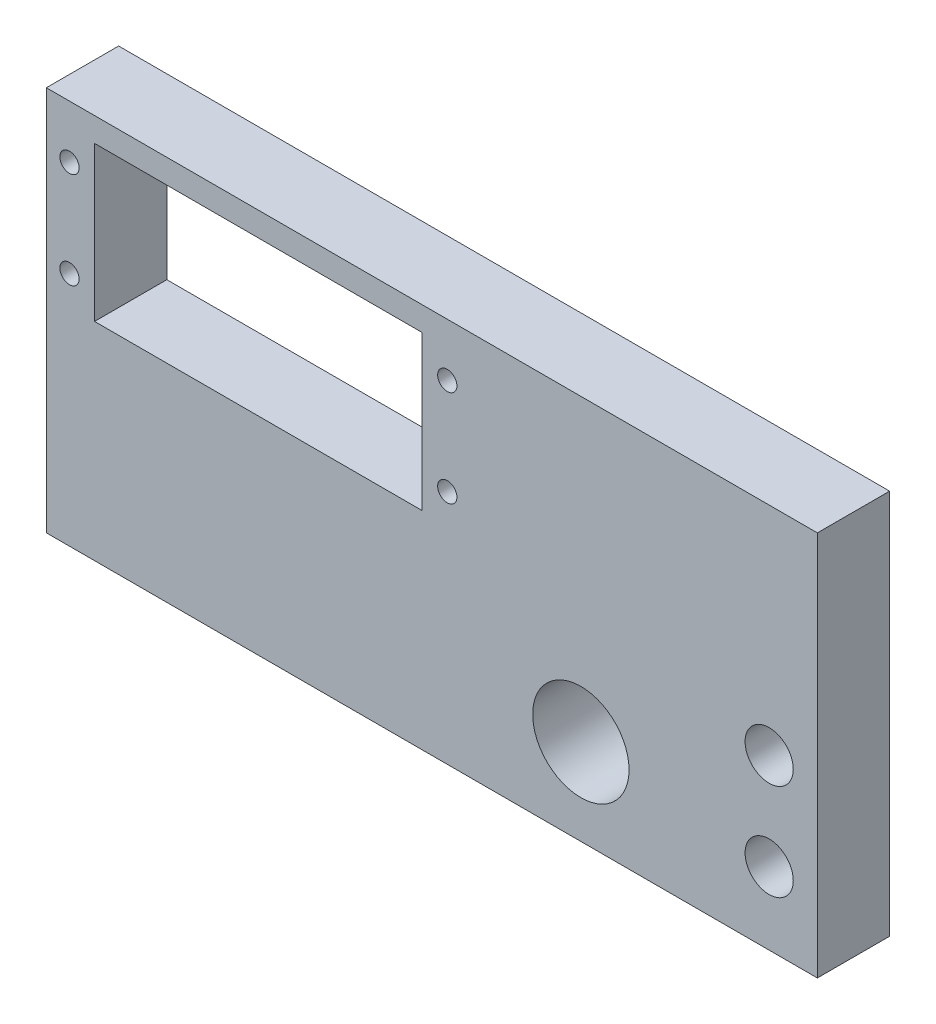
from build123d import *

# Parameters (mm, degrees)
SKETCH1_W           = 101.6
SKETCH1_H           = 50.8
SKETCH1_R           = 3.175
SKETCH1_R_2         = 1.27
SKETCH1_R_3         = 6.35
SKETCH1_W_2         = 43.18
SKETCH1_H_2         = 20.32
BOSS_EXTRUDE1_DEPTH = 9.525
SKETCH2_R           = 1.7272
CUT_EXTRUDE1_DEPTH  = 12.7


with BuildPart() as part:
    # Sketch1 → Boss-Extrude1 (new body)
    with BuildSketch(Plane.XY):
        with Locations((50.8, 25.4)):
            Rectangle(SKETCH1_W, SKETCH1_H)
        with Locations((95.25, 22.225)):
            Circle(SKETCH1_R, mode=Mode.SUBTRACT)
        with Locations((95.25, 9.525)):
            Circle(SKETCH1_R, mode=Mode.SUBTRACT)
        with Locations((3.048, 43.815)):
            Circle(SKETCH1_R_2, mode=Mode.SUBTRACT)
        with Locations((3.048, 31.115)):
            Circle(SKETCH1_R_2, mode=Mode.SUBTRACT)
        with Locations((52.832, 43.815)):
            Circle(SKETCH1_R_2, mode=Mode.SUBTRACT)
        with Locations((52.832, 31.115)):
            Circle(SKETCH1_R_2, mode=Mode.SUBTRACT)
        with Locations((70.435623446, 11.349127288)):
            Circle(SKETCH1_R_3, mode=Mode.SUBTRACT)
        with Locations((27.94, 37.465)):
            Rectangle(SKETCH1_W_2, SKETCH1_H_2, mode=Mode.SUBTRACT)
    extrude(amount=BOSS_EXTRUDE1_DEPTH)

    # Sketch2 → Cut-Extrude1 (cut)
    with BuildSketch(Plane.XZ):
        with Locations((60.2488, 4.7625)):
            Circle(SKETCH2_R)
        with Locations((79.2988, 4.7625)):
            Circle(SKETCH2_R)
    extrude(amount=-CUT_EXTRUDE1_DEPTH, mode=Mode.SUBTRACT)


solid = part.part
